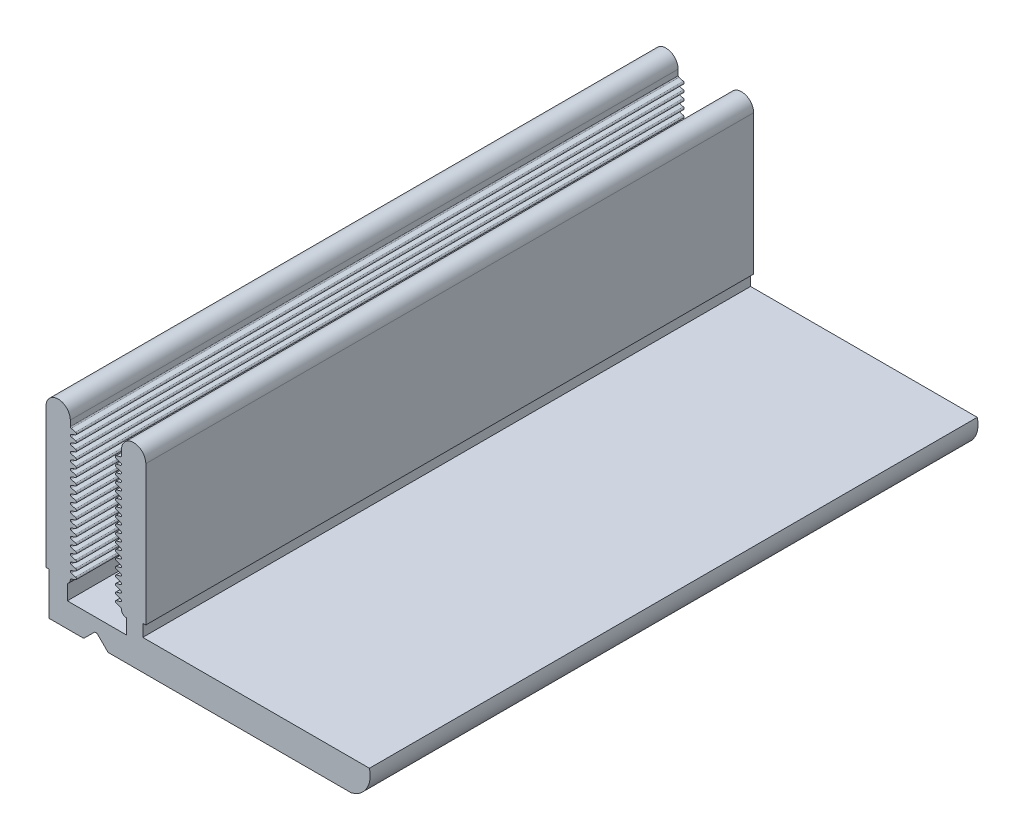
from build123d import *

# Parameters (mm, degrees)
EXTRUDE_2_DEPTH = 50


with BuildPart() as part:
    # Эскиз1 → Бобышка-Вытянуть2 (new body)
    with BuildSketch(Plane.XY):
        with BuildLine():
            Line((1.749425478, 2), (6.597450249, 2))
            Line((6.597450249, 2), (6.597450249, 3.219999818))
            ThreePointArc((6.597450249, 3.219999818), (6.318034469, 3.335737623), (6.202296664, 3.615153403))
            ThreePointArc((6.202296664, 3.615153403), (6.182496578, 3.671854652), (6.134631097, 3.708130963))
            Line((6.134631097, 3.708130963), (5.765036477, 3.845297648))
            ThreePointArc((5.765036477, 3.845297648), (5.699928757, 3.943484301), (5.77348091, 4.035515354))
            Line((5.77348091, 4.035515354), (6.128891922, 4.132594707))
            ThreePointArc((6.128891922, 4.132594707), (6.179848514, 4.165627509), (6.202296664, 4.222052865))
            ThreePointArc((6.202296664, 4.222052865), (6.182496578, 4.278754114), (6.134631097, 4.315030426))
            Line((6.134631097, 4.315030426), (5.765036477, 4.45219711))
            ThreePointArc((5.765036477, 4.45219711), (5.699928757, 4.550383763), (5.77348091, 4.642414817))
            Line((5.77348091, 4.642414817), (6.128891922, 4.739494169))
            ThreePointArc((6.128891922, 4.739494169), (6.179848514, 4.772526971), (6.202296664, 4.828952328))
            ThreePointArc((6.202296664, 4.828952328), (6.182496578, 4.885653577), (6.134631097, 4.921929888))
            Line((6.134631097, 4.921929888), (5.765036477, 5.059096573))
            ThreePointArc((5.765036477, 5.059096573), (5.699928757, 5.157283226), (5.77348091, 5.249314279))
            Line((5.77348091, 5.249314279), (6.128891922, 5.346393632))
            ThreePointArc((6.128891922, 5.346393632), (6.179848514, 5.379426434), (6.202296664, 5.43585179))
            ThreePointArc((6.202296664, 5.43585179), (6.182496578, 5.492553039), (6.134631097, 5.528829351))
            Line((6.134631097, 5.528829351), (5.765036477, 5.665996035))
            ThreePointArc((5.765036477, 5.665996035), (5.699928757, 5.764182688), (5.77348091, 5.856213742))
            Line((5.77348091, 5.856213742), (6.128891922, 5.953293094))
            ThreePointArc((6.128891922, 5.953293094), (6.179848514, 5.986325896), (6.202296664, 6.042751253))
            ThreePointArc((6.202296664, 6.042751253), (6.182496578, 6.099452502), (6.134631097, 6.135728813))
            Line((6.134631097, 6.135728813), (5.765036477, 6.272895498))
            ThreePointArc((5.765036477, 6.272895498), (5.699928757, 6.37108215), (5.77348091, 6.463113204))
            Line((5.77348091, 6.463113204), (6.128891922, 6.560192556))
            ThreePointArc((6.128891922, 6.560192556), (6.179848514, 6.593225359), (6.202296664, 6.649650715))
            ThreePointArc((6.202296664, 6.649650715), (6.182496578, 6.706351964), (6.134631097, 6.742628276))
            Line((6.134631097, 6.742628276), (5.765036477, 6.87979496))
            ThreePointArc((5.765036477, 6.87979496), (5.699928757, 6.977981613), (5.77348091, 7.070012667))
            Line((5.77348091, 7.070012667), (6.128891922, 7.167092019))
            ThreePointArc((6.128891922, 7.167092019), (6.179848514, 7.200124821), (6.202296664, 7.256550178))
            ThreePointArc((6.202296664, 7.256550178), (6.182496578, 7.313251427), (6.134631097, 7.349527738))
            Line((6.134631097, 7.349527738), (5.765036477, 7.486694423))
            ThreePointArc((5.765036477, 7.486694423), (5.699928757, 7.584881075), (5.77348091, 7.676912129))
            Line((5.77348091, 7.676912129), (6.128891922, 7.773991481))
            ThreePointArc((6.128891922, 7.773991481), (6.179848514, 7.807024284), (6.202296664, 7.86344964))
            ThreePointArc((6.202296664, 7.86344964), (6.182496578, 7.920150889), (6.134631097, 7.956427201))
            Line((6.134631097, 7.956427201), (5.765036477, 8.093593885))
            ThreePointArc((5.765036477, 8.093593885), (5.699928757, 8.191780538), (5.77348091, 8.283811592))
            Line((5.77348091, 8.283811592), (6.128891922, 8.380890944))
            ThreePointArc((6.128891922, 8.380890944), (6.179848514, 8.413923746), (6.202296664, 8.470349103))
            ThreePointArc((6.202296664, 8.470349103), (6.182496578, 8.527050352), (6.134631097, 8.563326663))
            Line((6.134631097, 8.563326663), (5.765036477, 8.700493348))
            ThreePointArc((5.765036477, 8.700493348), (5.699928757, 8.79868), (5.77348091, 8.890711054))
            Line((5.77348091, 8.890711054), (6.128891922, 8.987790406))
            ThreePointArc((6.128891922, 8.987790406), (6.179848514, 9.020823209), (6.202296664, 9.077248565))
            ThreePointArc((6.202296664, 9.077248565), (6.182496578, 9.133949814), (6.134631097, 9.170226126))
            Line((6.134631097, 9.170226126), (5.765036477, 9.30739281))
            ThreePointArc((5.765036477, 9.30739281), (5.699928757, 9.405579463), (5.77348091, 9.497610517))
            Line((5.77348091, 9.497610517), (6.128891922, 9.594689869))
            ThreePointArc((6.128891922, 9.594689869), (6.179848514, 9.627722671), (6.202296664, 9.684148028))
            ThreePointArc((6.202296664, 9.684148028), (6.182496578, 9.740849277), (6.134631097, 9.777125588))
            Line((6.134631097, 9.777125588), (5.765036477, 9.914292273))
            ThreePointArc((5.765036477, 9.914292273), (5.699928757, 10.012478925), (5.77348091, 10.104509979))
            Line((5.77348091, 10.104509979), (6.128891922, 10.201589331))
            ThreePointArc((6.128891922, 10.201589331), (6.179848514, 10.234622134), (6.202296664, 10.29104749))
            ThreePointArc((6.202296664, 10.29104749), (6.182496578, 10.347748739), (6.134631097, 10.384025051))
            Line((6.134631097, 10.384025051), (5.765036477, 10.521191735))
            ThreePointArc((5.765036477, 10.521191735), (5.699928757, 10.619378388), (5.77348091, 10.711409442))
            Line((5.77348091, 10.711409442), (6.128891922, 10.808488794))
            ThreePointArc((6.128891922, 10.808488794), (6.179848514, 10.841521596), (6.202296664, 10.897946953))
            ThreePointArc((6.202296664, 10.897946953), (6.182496578, 10.954648202), (6.134631097, 10.990924513))
            Line((6.134631097, 10.990924513), (5.765036477, 11.128091198))
            ThreePointArc((5.765036477, 11.128091198), (5.699928757, 11.22627785), (5.77348091, 11.318308904))
            Line((5.77348091, 11.318308904), (6.128891922, 11.415388256))
            ThreePointArc((6.128891922, 11.415388256), (6.179848514, 11.448421059), (6.202296664, 11.504846415))
            ThreePointArc((6.202296664, 11.504846415), (6.182496578, 11.561547664), (6.134631097, 11.597823976))
            Line((6.134631097, 11.597823976), (5.765036477, 11.73499066))
            ThreePointArc((5.765036477, 11.73499066), (5.699928757, 11.833177313), (5.77348091, 11.925208367))
            Line((5.77348091, 11.925208367), (6.128891922, 12.022287719))
            ThreePointArc((6.128891922, 12.022287719), (6.179848514, 12.055320521), (6.202296664, 12.111745877))
            ThreePointArc((6.202296664, 12.111745877), (6.182496578, 12.168447127), (6.134631097, 12.204723438))
            Line((6.134631097, 12.204723438), (5.765036477, 12.341890123))
            ThreePointArc((5.765036477, 12.341890123), (5.699928757, 12.440076775), (5.77348091, 12.532107829))
            Line((5.77348091, 12.532107829), (6.128891922, 12.629187181))
            ThreePointArc((6.128891922, 12.629187181), (6.179848514, 12.662219984), (6.202296664, 12.71864534))
            ThreePointArc((6.202296664, 12.71864534), (6.182496578, 12.775346589), (6.134631097, 12.811622901))
            Line((6.134631097, 12.811622901), (5.765036477, 12.948789585))
            ThreePointArc((5.765036477, 12.948789585), (5.699928757, 13.046976238), (5.77348091, 13.139007291))
            Line((5.77348091, 13.139007291), (6.128891922, 13.236086644))
            ThreePointArc((6.128891922, 13.236086644), (6.179848514, 13.269119446), (6.202296664, 13.325544802))
            ThreePointArc((6.202296664, 13.325544802), (6.182496578, 13.382246052), (6.134631097, 13.418522363))
            Line((6.134631097, 13.418522363), (5.765036477, 13.555689048))
            ThreePointArc((5.765036477, 13.555689048), (5.699928757, 13.6538757), (5.77348091, 13.745906754))
            Line((5.77348091, 13.745906754), (6.128891922, 13.842986106))
            ThreePointArc((6.128891922, 13.842986106), (6.179848514, 13.876018909), (6.202296664, 13.932444265))
            ThreePointArc((6.202296664, 13.932444265), (6.182496578, 13.989145514), (6.134631097, 14.025421826))
            Line((6.134631097, 14.025421826), (5.765036477, 14.16258851))
            ThreePointArc((5.765036477, 14.16258851), (5.699928757, 14.260775163), (5.77348091, 14.352806216))
            Line((5.77348091, 14.352806216), (6.128891922, 14.449885569))
            ThreePointArc((6.128891922, 14.449885569), (6.179848514, 14.482918371), (6.202296664, 14.539343727))
            Line((6.202296664, 14.539343727), (6.202296664, 15))
            ThreePointArc((6.202296664, 15), (7.202296664, 16), (8.202296664, 15))
            Line((8.202296664, 15), (8.202296664, 3.505592298))
            Line((8.202296664, 3.505592298), (7.952296664, 3.505592298))
            Line((7.952296664, 3.505592298), (7.952296664, 2.5))
            Line((7.952296664, 2.5), (16.283474858, 2.5))
            Line((16.283474858, 2.5), (26.597495831, 2.5))
            ThreePointArc((26.597495831, 2.5), (26.365262784, 0.939339828), (25.097495831, 0))
            Line((25.097495831, 0), (17.5, 0))
            Line((17.5, 0), (5.180338543, 0))
            ThreePointArc((5.180338543, 0), (5.103801857, 0.015224093), (5.038917187, 0.058578644))
            Line((5.038917187, 0.058578644), (4.238917187, 0.858578644))
            ThreePointArc((4.238917187, 0.858578644), (4.097495831, 0.917157288), (3.956074475, 0.858578644))
            Line((3.956074475, 0.858578644), (3.156074475, 0.058578644))
            ThreePointArc((3.156074475, 0.058578644), (3.091189805, 0.015224093), (3.014653118, 0))
            Line((3.014653118, 0), (0.242694998, 0))
            Line((0.242694998, 0), (0.242694998, 2.005592298))
            Line((0.242694998, 2.005592298), (0.242694998, 3.505592298))
            Line((0.242694998, 3.505592298), (-0.007305002, 3.505592298))
            Line((-0.007305002, 3.505592298), (-0.007305002, 15))
            ThreePointArc((-0.007305002, 15), (0.992694998, 16), (1.992694998, 15))
            Line((1.992694998, 15), (1.992694998, 14.539343727))
            ThreePointArc((1.992694998, 14.539343727), (2.015143148, 14.482918371), (2.06609974, 14.449885569))
            Line((2.06609974, 14.449885569), (2.421510752, 14.352806216))
            ThreePointArc((2.421510752, 14.352806216), (2.495062905, 14.260775163), (2.429955184, 14.16258851))
            Line((2.429955184, 14.16258851), (2.060360565, 14.025421826))
            ThreePointArc((2.060360565, 14.025421826), (2.012495084, 13.989145514), (1.992694998, 13.932444265))
            ThreePointArc((1.992694998, 13.932444265), (2.015143148, 13.876018909), (2.06609974, 13.842986106))
            Line((2.06609974, 13.842986106), (2.421510752, 13.745906754))
            ThreePointArc((2.421510752, 13.745906754), (2.495062905, 13.6538757), (2.429955184, 13.555689048))
            Line((2.429955184, 13.555689048), (2.060360565, 13.418522363))
            ThreePointArc((2.060360565, 13.418522363), (2.012495084, 13.382246052), (1.992694998, 13.325544802))
            ThreePointArc((1.992694998, 13.325544802), (2.015143148, 13.269119446), (2.06609974, 13.236086644))
            Line((2.06609974, 13.236086644), (2.421510752, 13.139007291))
            ThreePointArc((2.421510752, 13.139007291), (2.495062905, 13.046976238), (2.429955184, 12.948789585))
            Line((2.429955184, 12.948789585), (2.060360565, 12.811622901))
            ThreePointArc((2.060360565, 12.811622901), (2.012495084, 12.775346589), (1.992694998, 12.71864534))
            ThreePointArc((1.992694998, 12.71864534), (2.015143148, 12.662219984), (2.06609974, 12.629187181))
            Line((2.06609974, 12.629187181), (2.421510752, 12.532107829))
            ThreePointArc((2.421510752, 12.532107829), (2.495062905, 12.440076775), (2.429955184, 12.341890123))
            Line((2.429955184, 12.341890123), (2.060360565, 12.204723438))
            ThreePointArc((2.060360565, 12.204723438), (2.012495084, 12.168447127), (1.992694998, 12.111745877))
            ThreePointArc((1.992694998, 12.111745877), (2.015143148, 12.055320521), (2.06609974, 12.022287719))
            Line((2.06609974, 12.022287719), (2.421510752, 11.925208367))
            ThreePointArc((2.421510752, 11.925208367), (2.495062905, 11.833177313), (2.429955184, 11.73499066))
            Line((2.429955184, 11.73499066), (2.060360565, 11.597823976))
            ThreePointArc((2.060360565, 11.597823976), (2.012495084, 11.561547664), (1.992694998, 11.504846415))
            ThreePointArc((1.992694998, 11.504846415), (2.015143148, 11.448421059), (2.06609974, 11.415388256))
            Line((2.06609974, 11.415388256), (2.421510752, 11.318308904))
            ThreePointArc((2.421510752, 11.318308904), (2.495062905, 11.22627785), (2.429955184, 11.128091198))
            Line((2.429955184, 11.128091198), (2.060360565, 10.990924513))
            ThreePointArc((2.060360565, 10.990924513), (2.012495084, 10.954648202), (1.992694998, 10.897946953))
            ThreePointArc((1.992694998, 10.897946953), (2.015143148, 10.841521596), (2.06609974, 10.808488794))
            Line((2.06609974, 10.808488794), (2.421510752, 10.711409442))
            ThreePointArc((2.421510752, 10.711409442), (2.495062905, 10.619378388), (2.429955184, 10.521191735))
            Line((2.429955184, 10.521191735), (2.060360565, 10.384025051))
            ThreePointArc((2.060360565, 10.384025051), (2.012495084, 10.347748739), (1.992694998, 10.29104749))
            ThreePointArc((1.992694998, 10.29104749), (2.015143148, 10.234622134), (2.06609974, 10.201589331))
            Line((2.06609974, 10.201589331), (2.421510752, 10.104509979))
            ThreePointArc((2.421510752, 10.104509979), (2.495062905, 10.012478925), (2.429955184, 9.914292273))
            Line((2.429955184, 9.914292273), (2.060360565, 9.777125588))
            ThreePointArc((2.060360565, 9.777125588), (2.012495084, 9.740849277), (1.992694998, 9.684148028))
            ThreePointArc((1.992694998, 9.684148028), (2.015143148, 9.627722671), (2.06609974, 9.594689869))
            Line((2.06609974, 9.594689869), (2.421510752, 9.497610517))
            ThreePointArc((2.421510752, 9.497610517), (2.495062905, 9.405579463), (2.429955184, 9.30739281))
            Line((2.429955184, 9.30739281), (2.060360565, 9.170226126))
            ThreePointArc((2.060360565, 9.170226126), (2.012495084, 9.133949814), (1.992694998, 9.077248565))
            ThreePointArc((1.992694998, 9.077248565), (2.015143148, 9.020823209), (2.06609974, 8.987790406))
            Line((2.06609974, 8.987790406), (2.421510752, 8.890711054))
            ThreePointArc((2.421510752, 8.890711054), (2.495062905, 8.79868), (2.429955184, 8.700493348))
            Line((2.429955184, 8.700493348), (2.060360565, 8.563326663))
            ThreePointArc((2.060360565, 8.563326663), (2.012495084, 8.527050352), (1.992694998, 8.470349103))
            ThreePointArc((1.992694998, 8.470349103), (2.015143148, 8.413923746), (2.06609974, 8.380890944))
            Line((2.06609974, 8.380890944), (2.421510752, 8.283811592))
            ThreePointArc((2.421510752, 8.283811592), (2.495062905, 8.191780538), (2.429955184, 8.093593885))
            Line((2.429955184, 8.093593885), (2.060360565, 7.956427201))
            ThreePointArc((2.060360565, 7.956427201), (2.012495084, 7.920150889), (1.992694998, 7.86344964))
            ThreePointArc((1.992694998, 7.86344964), (2.015143148, 7.807024284), (2.06609974, 7.773991481))
            Line((2.06609974, 7.773991481), (2.421510752, 7.676912129))
            ThreePointArc((2.421510752, 7.676912129), (2.495062905, 7.584881075), (2.429955184, 7.486694423))
            Line((2.429955184, 7.486694423), (2.060360565, 7.349527738))
            ThreePointArc((2.060360565, 7.349527738), (2.012495084, 7.313251427), (1.992694998, 7.256550178))
            ThreePointArc((1.992694998, 7.256550178), (2.015143148, 7.200124821), (2.06609974, 7.167092019))
            Line((2.06609974, 7.167092019), (2.421510752, 7.070012667))
            ThreePointArc((2.421510752, 7.070012667), (2.495062905, 6.977981613), (2.429955184, 6.87979496))
            Line((2.429955184, 6.87979496), (2.060360565, 6.742628276))
            ThreePointArc((2.060360565, 6.742628276), (2.012495084, 6.706351964), (1.992694998, 6.649650715))
            ThreePointArc((1.992694998, 6.649650715), (2.015143148, 6.593225359), (2.06609974, 6.560192556))
            Line((2.06609974, 6.560192556), (2.421510752, 6.463113204))
            ThreePointArc((2.421510752, 6.463113204), (2.495062905, 6.37108215), (2.429955184, 6.272895498))
            Line((2.429955184, 6.272895498), (2.060360565, 6.135728813))
            ThreePointArc((2.060360565, 6.135728813), (2.012495084, 6.099452502), (1.992694998, 6.042751253))
            ThreePointArc((1.992694998, 6.042751253), (2.015143148, 5.986325896), (2.06609974, 5.953293094))
            Line((2.06609974, 5.953293094), (2.421510752, 5.856213742))
            ThreePointArc((2.421510752, 5.856213742), (2.495062905, 5.764182688), (2.429955184, 5.665996035))
            Line((2.429955184, 5.665996035), (2.060360565, 5.528829351))
            ThreePointArc((2.060360565, 5.528829351), (2.012495084, 5.492553039), (1.992694998, 5.43585179))
            ThreePointArc((1.992694998, 5.43585179), (2.015143148, 5.379426434), (2.06609974, 5.346393632))
            Line((2.06609974, 5.346393632), (2.421510752, 5.249314279))
            ThreePointArc((2.421510752, 5.249314279), (2.495062905, 5.157283226), (2.429955184, 5.059096573))
            Line((2.429955184, 5.059096573), (2.060360565, 4.921929888))
            ThreePointArc((2.060360565, 4.921929888), (2.012495084, 4.885653577), (1.992694998, 4.828952328))
            ThreePointArc((1.992694998, 4.828952328), (2.015143148, 4.772526971), (2.06609974, 4.739494169))
            Line((2.06609974, 4.739494169), (2.421510752, 4.642414817))
            ThreePointArc((2.421510752, 4.642414817), (2.495062905, 4.550383763), (2.429955184, 4.45219711))
            Line((2.429955184, 4.45219711), (2.060360565, 4.315030426))
            ThreePointArc((2.060360565, 4.315030426), (2.012495084, 4.278754114), (1.992694998, 4.222052865))
            ThreePointArc((1.992694998, 4.222052865), (2.015143148, 4.165627509), (2.06609974, 4.132594707))
            Line((2.06609974, 4.132594707), (2.421510752, 4.035515354))
            ThreePointArc((2.421510752, 4.035515354), (2.495062905, 3.943484301), (2.429955184, 3.845297648))
            Line((2.429955184, 3.845297648), (2.060360565, 3.708130963))
            ThreePointArc((2.060360565, 3.708130963), (2.012495084, 3.671854652), (1.992694998, 3.615153403))
            ThreePointArc((1.992694998, 3.615153403), (1.926299598, 3.39591743), (1.749425478, 3.250355395))
            Line((1.749425478, 3.250355395), (1.749425478, 2))
        make_face()
    extrude(amount=EXTRUDE_2_DEPTH)


solid = part.part
